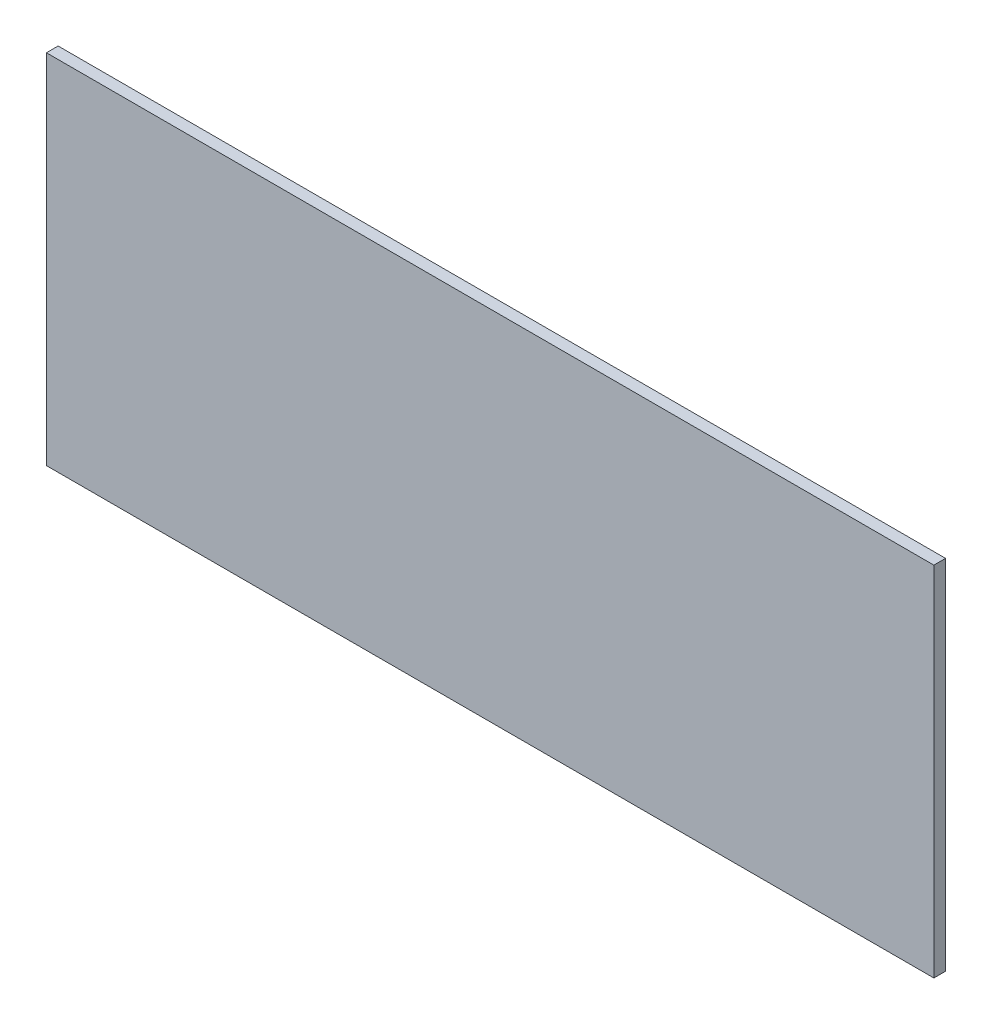
from build123d import *

# Parameters (mm, degrees)
SKETCH1_W           = 1365
SKETCH1_H           = 550
BOSS_EXTRUDE1_DEPTH = 18


with BuildPart() as part:
    # Sketch1 → Boss-Extrude1 (new body)
    with BuildSketch(Plane.XY):
        Rectangle(SKETCH1_W, SKETCH1_H)
    extrude(amount=BOSS_EXTRUDE1_DEPTH)


solid = part.part
